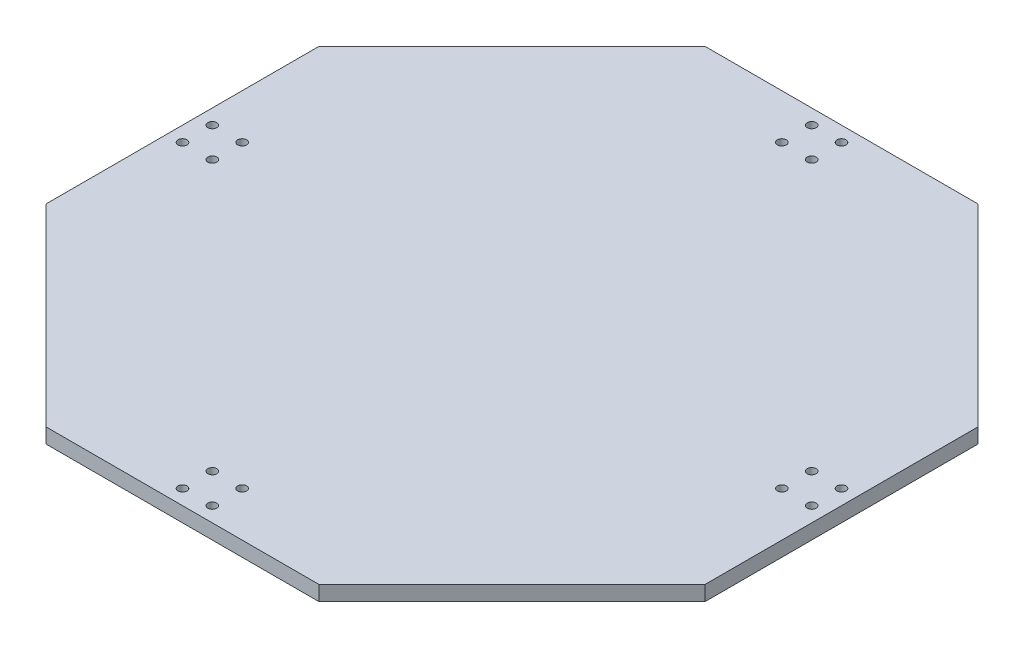
from build123d import *

# Parameters (mm, degrees)
SKETCH_1_R      = 1.5
EXTRUDE_1_DEPTH = 5


with BuildPart() as part:
    # 스케치1 → 보스-돌출1 (new body)
    with BuildSketch(Plane(origin=(0, 0, 0), x_dir=(1, 0, 0), z_dir=(0, 1, 0))):
        Polygon((45.770598642, -110.5), (110.5, -45.770598642), (110.5, 45.770598642), (45.770598642, 110.5), (-45.770598642, 110.5), (-110.5, 45.770598642), (-110.5, -45.770598642), (-45.770598642, -110.5), align=None)
        with Locations((-5, 105.5)):
            Circle(SKETCH_1_R, mode=Mode.SUBTRACT)
        with Locations((-5, 95.5)):
            Circle(SKETCH_1_R, mode=Mode.SUBTRACT)
        with Locations((5, 95.5)):
            Circle(SKETCH_1_R, mode=Mode.SUBTRACT)
        with Locations((5, 105.5)):
            Circle(SKETCH_1_R, mode=Mode.SUBTRACT)
        with Locations((105.5, 5)):
            Circle(SKETCH_1_R, mode=Mode.SUBTRACT)
        with Locations((95.5, 5)):
            Circle(SKETCH_1_R, mode=Mode.SUBTRACT)
        with Locations((95.5, -5)):
            Circle(SKETCH_1_R, mode=Mode.SUBTRACT)
        with Locations((105.5, -5)):
            Circle(SKETCH_1_R, mode=Mode.SUBTRACT)
        with Locations((5, -105.5)):
            Circle(SKETCH_1_R, mode=Mode.SUBTRACT)
        with Locations((5, -95.5)):
            Circle(SKETCH_1_R, mode=Mode.SUBTRACT)
        with Locations((-5, -95.5)):
            Circle(SKETCH_1_R, mode=Mode.SUBTRACT)
        with Locations((-5, -105.5)):
            Circle(SKETCH_1_R, mode=Mode.SUBTRACT)
        with Locations((-105.5, -5)):
            Circle(SKETCH_1_R, mode=Mode.SUBTRACT)
        with Locations((-95.5, -5)):
            Circle(SKETCH_1_R, mode=Mode.SUBTRACT)
        with Locations((-95.5, 5)):
            Circle(SKETCH_1_R, mode=Mode.SUBTRACT)
        with Locations((-105.5, 5)):
            Circle(SKETCH_1_R, mode=Mode.SUBTRACT)
    extrude(amount=EXTRUDE_1_DEPTH)


solid = part.part
